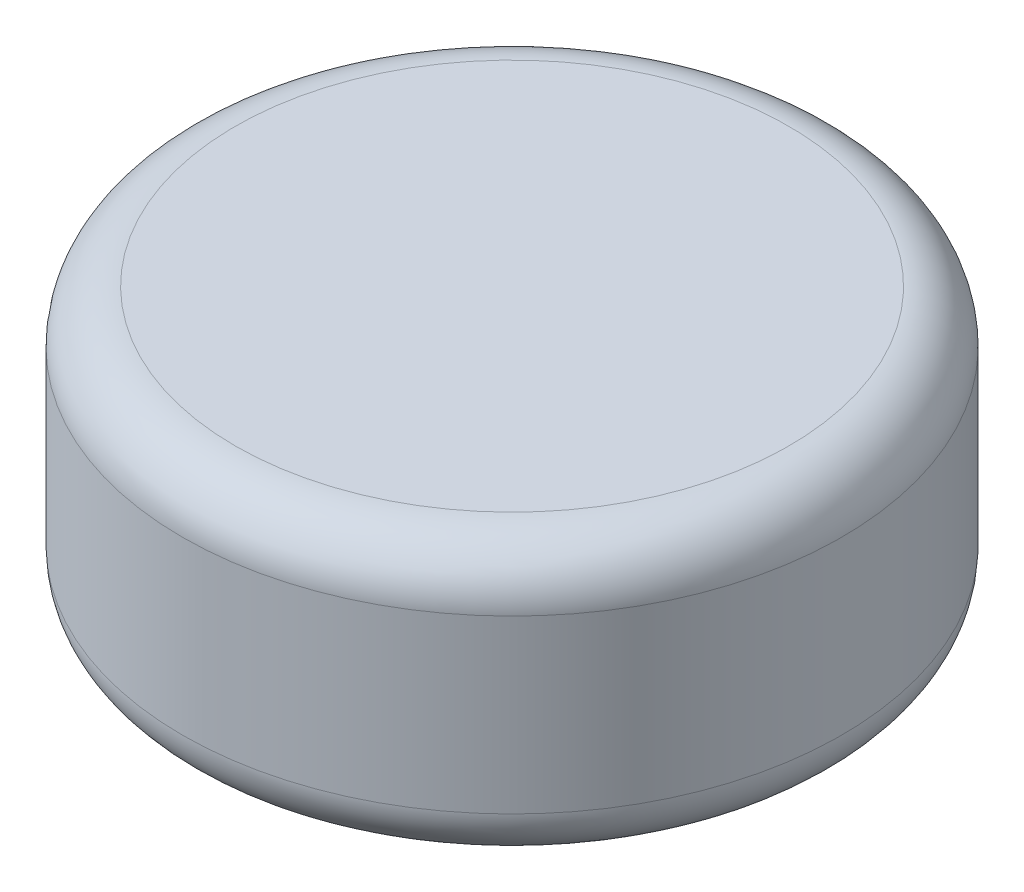
from build123d import *

# Parameters (mm, degrees)
SKETCH1_R           = 9.525
BOSS_EXTRUDE1_DEPTH = 4.0005
SKETCH1_3_W         = 6.731
SKETCH1_3_H         = 6.731
CUT_EXTRUDE1_DEPTH  = 3.3655
FILLET1_R           = 1.524


with BuildPart() as part:
    # Sketch1 → Boss-Extrude1 (new, symmetric)
    with BuildSketch(Plane(origin=(0, 0, 0), x_dir=(1, 0, 0), z_dir=(0, 1, 0))):
        Circle(SKETCH1_R)
    extrude(amount=BOSS_EXTRUDE1_DEPTH, both=True)

    # Sketch1_3 → Cut-Extrude1 (cut, symmetric)
    with BuildSketch(Plane(origin=(0, 0, 0), x_dir=(1, 0, 0), z_dir=(0, 1, 0))):
        Rectangle(SKETCH1_3_W, SKETCH1_3_H)
    extrude(amount=CUT_EXTRUDE1_DEPTH, both=True, mode=Mode.SUBTRACT)

    # Fillet1
    fillet1_edges = [part.edges().sort_by_distance(p)[0] for p in [
        (-9.525, 4.0005, 0),
        (-9.525, -4.0005, 0),
    ]]
    fillet(fillet1_edges, radius=FILLET1_R)


solid = part.part
